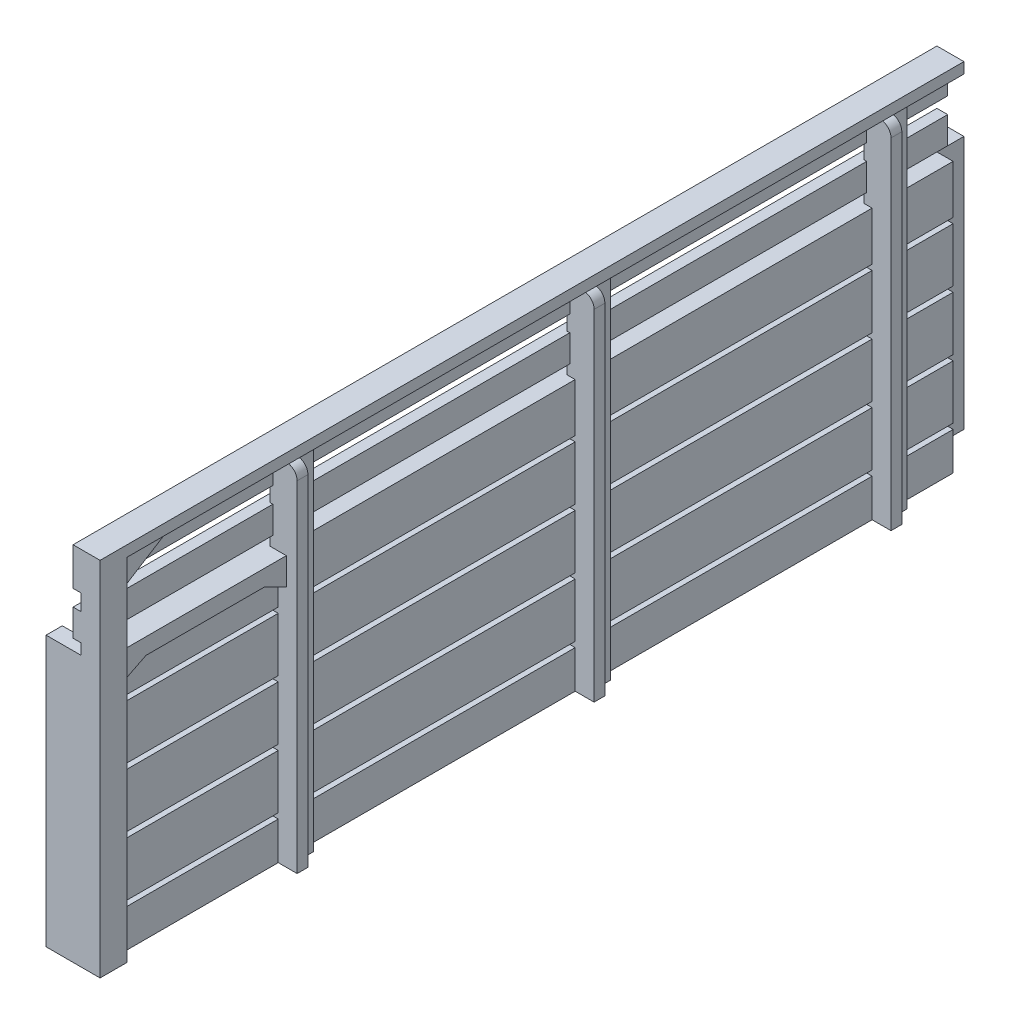
from build123d import *

# Parameters (mm, degrees)
SKETCH1_W            = 160
SKETCH1_H            = 50
BOSS_EXTRUDE1_DEPTH  = 3
SKETCH2_W            = 160
SKETCH2_H            = 1
CUT_EXTRUDE1_DEPTH   = 1.5
SKETCH3_W            = 5
SKETCH3_H            = 65
BOSS_EXTRUDE2_DEPTH  = 1.5
SKETCH4_W            = 160
SKETCH4_H            = 3
BOSS_EXTRUDE3_DEPTH  = 5
SKETCH5_W            = 3
SKETCH5_H            = 47
BOSS_EXTRUDE4_DEPTH  = 5
SKETCH6_W            = 160
SKETCH6_H            = 5
BOSS_EXTRUDE5_DEPTH  = 2
SKETCH7_W            = 2
SKETCH7_H            = 65
BOSS_EXTRUDE6_DEPTH  = 2
FILLET1_R            = 2
SKETCH8_W            = 5
SKETCH8_H            = 160
BOSS_EXTRUDE7_DEPTH  = 2
SKETCH9_W            = 10
SKETCH9_H            = 47
BOSS_EXTRUDE8_DEPTH  = 5
BOSS_EXTRUDE9_DEPTH  = 2.5
BOSS_EXTRUDE10_DEPTH = 1.5
SKETCH12_W           = 4.967149052
SKETCH12_H           = 65
BOSS_EXTRUDE11_DEPTH = 0.5


with BuildPart() as part:
    # Sketch1 → Boss-Extrude1 (new body)
    with BuildSketch(Plane(origin=(0, 0, 0), x_dir=(0, 0, -1), z_dir=(1, 0, 0))):
        Rectangle(SKETCH1_W, SKETCH1_H)
    extrude(amount=BOSS_EXTRUDE1_DEPTH)

    # Sketch2 → Cut-Extrude1 (cut)
    with BuildSketch(Plane(origin=(3, 0, 0), x_dir=(0, 0, -1), z_dir=(1, 0, 0))):
        with Locations((0, -17.5)):
            Rectangle(SKETCH2_W, SKETCH2_H)
        with Locations((0, -6.5)):
            Rectangle(SKETCH2_W, SKETCH2_H)
        with Locations((0, 4.5)):
            Rectangle(SKETCH2_W, SKETCH2_H)
        with Locations((0, 15.5)):
            Rectangle(SKETCH2_W, SKETCH2_H)
    extrude(amount=-CUT_EXTRUDE1_DEPTH, mode=Mode.SUBTRACT)

    # Sketch3 → Boss-Extrude2 (add, symmetric)
    with BuildSketch(Plane(origin=(3, 0, 0), x_dir=(0, 0, -1), z_dir=(1, 0, 0))):
        with Locations((-77.5, 7.5)):
            Rectangle(SKETCH3_W, SKETCH3_H)
        with Locations((-42.5, 7.5)):
            Rectangle(SKETCH3_W, SKETCH3_H)
        with Locations((12.5, 7.5)):
            Rectangle(SKETCH3_W, SKETCH3_H)
        with Locations((67.5, 7.5)):
            Rectangle(SKETCH3_W, SKETCH3_H)
    extrude(amount=BOSS_EXTRUDE2_DEPTH, both=True)

    # Sketch4 → Boss-Extrude3 (add)
    with BuildSketch(Plane.ZY):
        with Locations((0, -23.5)):
            Rectangle(SKETCH4_W, SKETCH4_H)
    extrude(amount=BOSS_EXTRUDE3_DEPTH)

    # Sketch5 → Boss-Extrude4 (add)
    with BuildSketch(Plane.ZY):
        with Locations((78.5, 1.5)):
            Rectangle(SKETCH5_W, SKETCH5_H)
    extrude(amount=BOSS_EXTRUDE4_DEPTH)

    # Sketch6 → Boss-Extrude5 (add)
    with BuildSketch(Plane.ZY):
        with Locations((0, 29.5)):
            Rectangle(SKETCH6_W, SKETCH6_H)
        with Locations((0, 37.5)):
            Rectangle(SKETCH6_W, SKETCH6_H)
    extrude(amount=-BOSS_EXTRUDE5_DEPTH)

    # Sketch7 → Boss-Extrude6 (add)
    with BuildSketch(Plane(origin=(4.5, 0, 0), x_dir=(0, 0, -1), z_dir=(1, 0, 0))):
        with Locations((-44, 7.5)):
            Rectangle(SKETCH7_W, SKETCH7_H)
        with Locations((11, 7.5)):
            Rectangle(SKETCH7_W, SKETCH7_H)
        with Locations((66, 7.5)):
            Rectangle(SKETCH7_W, SKETCH7_H)
    extrude(amount=BOSS_EXTRUDE6_DEPTH)

    # Fillet1
    fillet1_edges = [part.edges().sort_by_distance(p)[0] for p in [
        (6.5, 40, -66),
        (6.5, 40, -11),
        (6.5, 40, 44),
    ]]
    fillet(fillet1_edges, radius=FILLET1_R)

    # Sketch8 → Boss-Extrude7 (add)
    with BuildSketch(Plane(origin=(0, 40, 0), x_dir=(1, 0, 0), z_dir=(0, 1, 0))):
        with Locations((2.5, 0)):
            Rectangle(SKETCH8_W, SKETCH8_H)
    extrude(amount=BOSS_EXTRUDE7_DEPTH)

    # Sketch9 → Boss-Extrude8 (add)
    with BuildSketch(Plane.ZY):
        with Locations((-80, 1.5)):
            Rectangle(SKETCH9_W, SKETCH9_H)
    extrude(amount=BOSS_EXTRUDE8_DEPTH)

    # Sketch10 → Boss-Extrude9 (add)
    with BuildSketch(Plane(origin=(2, 0, 0), x_dir=(0, 0, -1), z_dir=(1, 0, 0))):
        Polygon((-75, 40), (-75, 35), (-67, 40), align=None)
    extrude(amount=BOSS_EXTRUDE9_DEPTH)

    # Sketch11 → Boss-Extrude10 (add)
    with BuildSketch(Plane(origin=(3, 0, 0), x_dir=(0, 0, -1), z_dir=(1, 0, 0))):
        Polygon((-45, 25), (-75, 25), (-75, 20), (-71, 22), (-49, 22), (-45, 20), align=None)
    extrude(amount=BOSS_EXTRUDE10_DEPTH)

    # Sketch12 → Boss-Extrude11 (add)
    with BuildSketch(Plane(origin=(4.5, 0, 0), x_dir=(0, 0, -1), z_dir=(1, 0, 0))):
        with Locations((-77.516425474, 7.5)):
            Rectangle(SKETCH12_W, SKETCH12_H)
    extrude(amount=BOSS_EXTRUDE11_DEPTH)


solid = part.part
